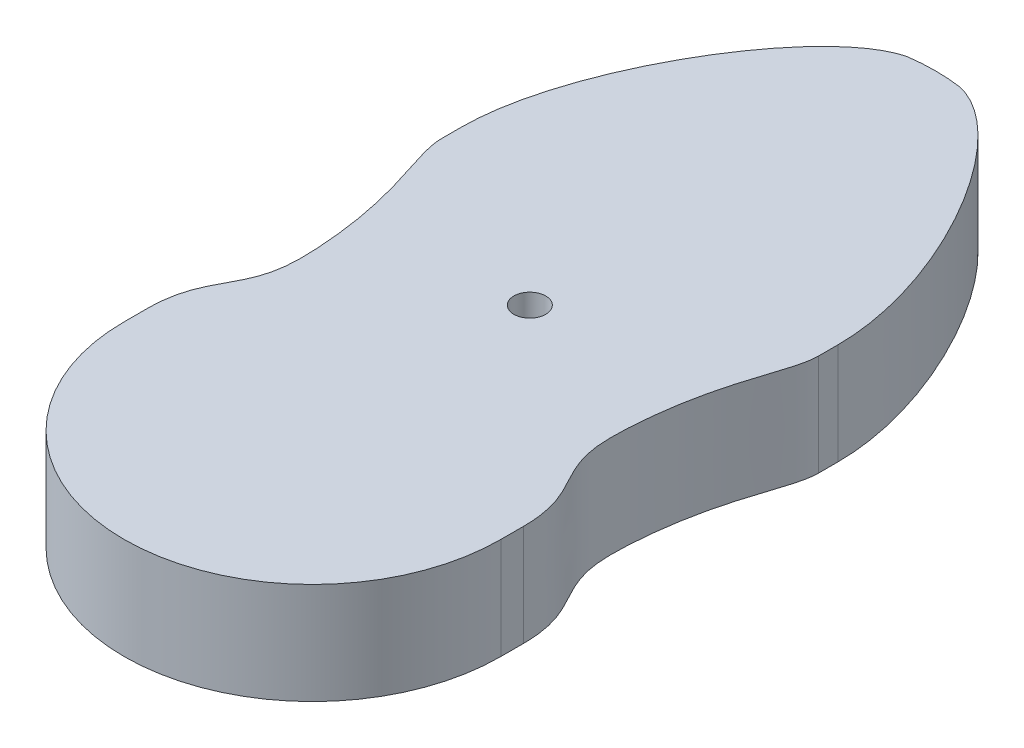
from build123d import *

# Parameters (mm, degrees)
BOSS_EXTRUDE1_DEPTH   = 35
M10_CLEARANCE_HOLE1_D = 11


with BuildPart() as part:
    # Sketch1 → Boss-Extrude1 (new body)
    with BuildSketch(Plane(origin=(0, 0, 0), x_dir=(1, 0, 0), z_dir=(0, 1, 0))):
        with BuildLine():
            Line((65, 34.564378512), (65, 41.31320725))
            add(Edge.make_bspline(
                [(65, 41.31320725), (65, 79.431268024), (31.724329751, 134.359342402), (8.994063072, 139.37473751)],
                knots=[0, 0, 0, 0, 0.953598716, 0.953598716, 0.953598716, 0.953598716], degree=3))
            ThreePointArc((8.994063072, 139.37473751), (7.377306472, 139.579991865), (5.755912154, 139.744648237))
            ThreePointArc((5.755912154, 139.744648237), (0, 140), (-5.755912154, 139.744648237))
            ThreePointArc((-5.755912154, 139.744648237), (-7.377306472, 139.579991865), (-8.994063072, 139.37473751))
            add(Edge.make_bspline(
                [(-65, 41.31320725), (-65, 79.431268024), (-31.724329751, 134.359342402), (-8.994063072, 139.37473751)],
                knots=[0, 0, 0, 0, 0.953598716, 0.953598716, 0.953598716, 0.953598716], degree=3))
            Line((-65, 41.31320725), (-65, 34.564378512))
            add(Edge.make_bspline(
                [(-65, 34.564378512), (-65, 25.304446618), (-54.875938022, 10.00088171), (-52.508224213, -44.666118343), (-65, -48.330846971), (-65, -67.177210158)],
                knots=[0, 0, 0, 0, 0.557561402, 0.657561402, 1, 1, 1, 1], degree=3))
            Line((-65, -67.177210158), (-65, -75))
            ThreePointArc((-65, -75), (0, -140), (65, -75))
            Line((65, -75), (65, -67.177210158))
            add(Edge.make_bspline(
                [(65, 34.564378512), (65, 25.304446618), (54.875938022, 10.00088171), (52.508224213, -44.666118343), (65, -48.330846971), (65, -67.177210158)],
                knots=[0, 0, 0, 0, 0.557561402, 0.657561402, 1, 1, 1, 1], degree=3))
        make_face()
    extrude(amount=BOSS_EXTRUDE1_DEPTH)

    # M10 Clearance Hole1 (through all)
    with Locations(Plane(origin=(0, 35, 0), x_dir=(1, 0, 0), z_dir=(0, 1, 0))):
        with Locations((0, 0)):
            Hole(M10_CLEARANCE_HOLE1_D / 2)


solid = part.part
